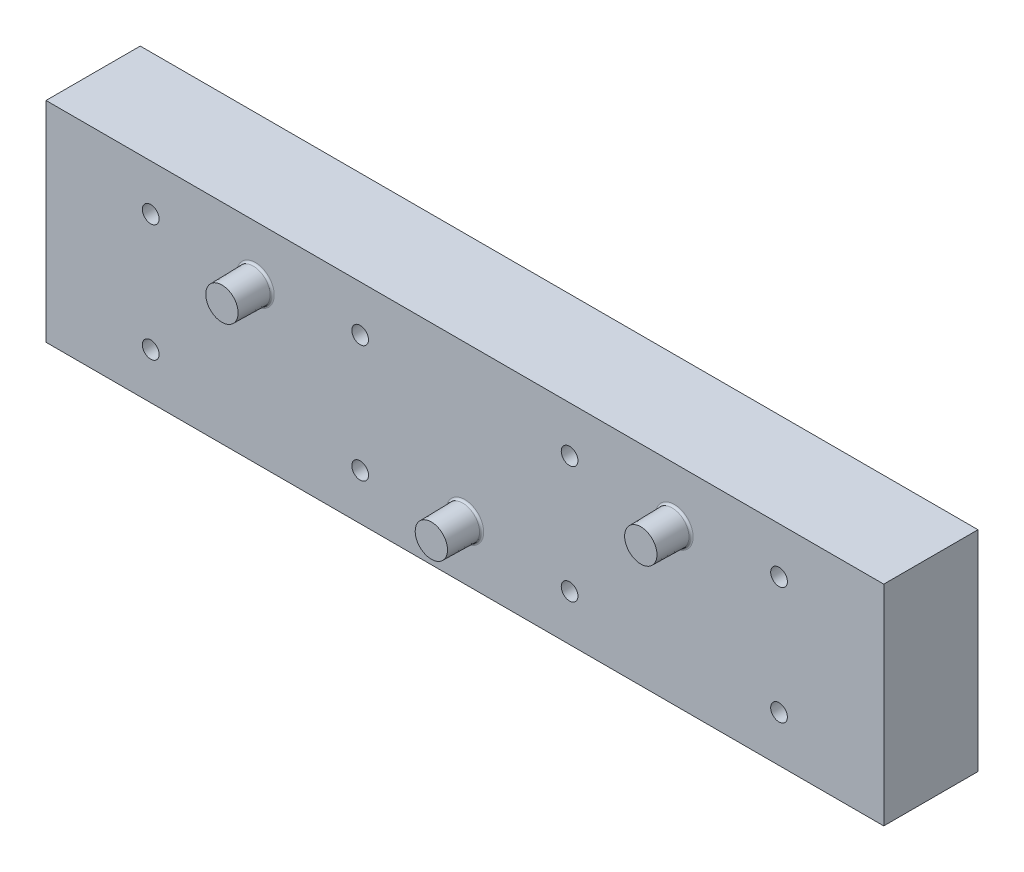
from build123d import *

# Parameters (mm, degrees)
SKETCH1_W           = 100
SKETCH1_H           = 11.25
BOSS_EXTRUDE1_DEPTH = 12.5
SKETCH3_R           = 2
BOSS_EXTRUDE2_DEPTH = 4
DRAFT1_ANGLE        = 1
SKETCH4_R           = 1.5875
CUT_EXTRUDE3_DEPTH  = 53.752369615
LPATTERN2_COUNT     = 4
LPATTERN2_PITCH     = 25
DRAFT3_ANGLE        = 3
FILLET2_R           = 0.25


with BuildPart() as part:
    # Sketch1 → Boss-Extrude1 (new, symmetric)
    with BuildSketch(Plane(origin=(0, 0, 0), x_dir=(1, 0, 0), z_dir=(0, 1, 0))):
        with Locations((0, 5.625)):
            Rectangle(SKETCH1_W, SKETCH1_H)
    extrude(amount=BOSS_EXTRUDE1_DEPTH, both=True)

    # Sketch3 → Boss-Extrude2 (add)
    with BuildSketch(Plane.XY):
        with Locations((-25, 6)):
            Circle(SKETCH3_R)
        with Locations((25, 6)):
            Circle(SKETCH3_R)
        with Locations((0, -6)):
            Circle(SKETCH3_R)
    extrude(amount=BOSS_EXTRUDE2_DEPTH)

    # Draft1
    draft1_faces = [part.faces().sort_by_distance(p)[0] for p in [
        (23, 6, 2),
        (-2, -6, 2),
        (-27, 6, 2),
    ]]
    draft(draft1_faces, Plane(origin=(-50, 12.5, 0), x_dir=(1, 0, 0), z_dir=(0, 0, 1)), DRAFT1_ANGLE)

    # Sketch4 → Cut-Extrude3 (cut, through all)
    with BuildSketch(Plane.XY):
        with Locations((-37.5, 7)):
            Circle(SKETCH4_R)
        with Locations((-37.5, -7)):
            Circle(SKETCH4_R)
    cut_extrude3 = extrude(amount=-CUT_EXTRUDE3_DEPTH, mode=Mode.SUBTRACT)

    # LPattern2: Cut-Extrude3 ×4
    with Locations(*[(i * LPATTERN2_PITCH, 0, 0) for i in range(1, LPATTERN2_COUNT)]):
        add(cut_extrude3, mode=Mode.SUBTRACT)

    # Draft3
    draft3_faces = [part.faces().sort_by_distance(p)[0] for p in [
        (35.9125, 7, -5.625),
        (35.9125, -7, -5.625),
        (10.9125, 7, -5.625),
        (10.9125, -7, -5.625),
        (-14.0875, -7, -5.625),
        (-14.0875, 7, -5.625),
        (-39.0875, -7, -5.625),
        (-39.0875, 7, -5.625),
    ]]
    draft(draft3_faces, Plane(origin=(-50, 12.5, -11.25), x_dir=(-1, 0, 0), z_dir=(0, 0, -1)), DRAFT3_ANGLE)

    # Fillet2
    fillet2_edges = [part.edges().sort_by_distance(p)[0] for p in [
        (23, 6, 0),
        (-2, -6, 0),
        (-27, 6, 0),
    ]]
    fillet(fillet2_edges, radius=FILLET2_R)


solid = part.part
